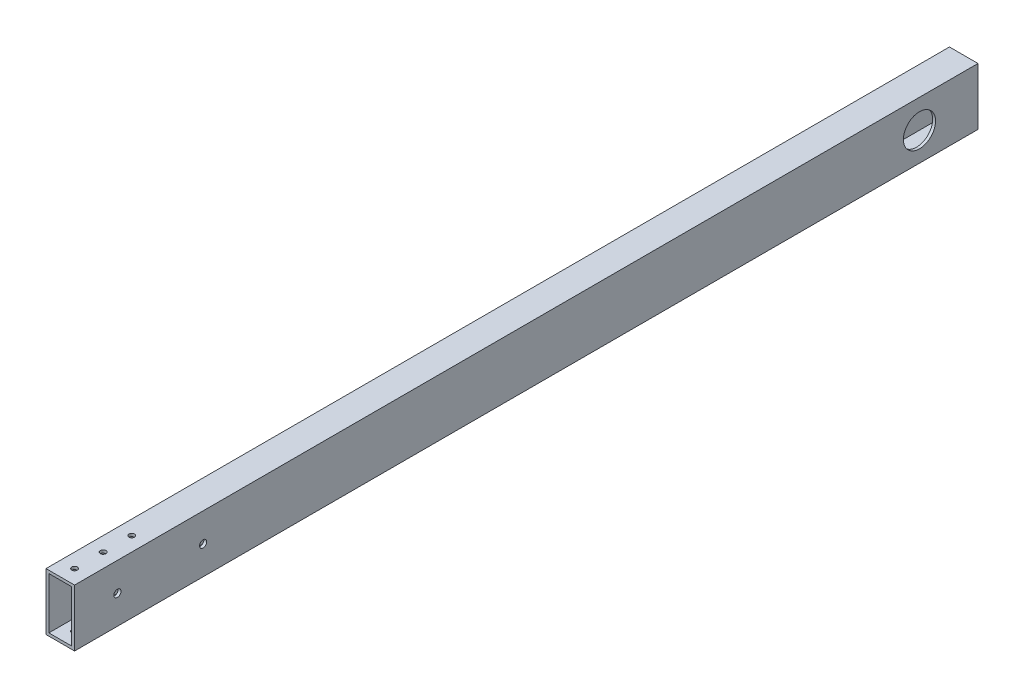
from build123d import *

# Parameters (mm, degrees)
SKETCH1_W           = 25.4
SKETCH1_H           = 50.8
SKETCH1_W_2         = 20.32
SKETCH1_H_2         = 45.72
EXTRUDE_THIN1_DEPTH = 401.6375
SKETCH2_R           = 14.2875
CUT_EXTRUDE1_DEPTH  = 26.4
SKETCH3_R           = 3.175
CUT_EXTRUDE2_DEPTH  = 26.4
SKETCH5_R           = 2.4765
CUT_EXTRUDE4_DEPTH  = 3.81
SKETCH7_R           = 2.4765
CUT_EXTRUDE5_DEPTH  = 51.8
SKETCH8_R           = 2.476504233
CUT_EXTRUDE6_DEPTH  = 3.81


with BuildPart() as part:
    # Sketch1 → Extrude-Thin1 (new body, symmetric)
    with BuildSketch(Plane.XY):
        Rectangle(SKETCH1_W, SKETCH1_H)
        Rectangle(SKETCH1_W_2, SKETCH1_H_2, mode=Mode.SUBTRACT)
    extrude(amount=EXTRUDE_THIN1_DEPTH, both=True)

    # Sketch2 → Cut-Extrude1 (cut, through all)
    with BuildSketch(Plane.ZY.offset(12.7)):
        with Locations((-349.59481695, 0)):
            Circle(SKETCH2_R)
    extrude(amount=-CUT_EXTRUDE1_DEPTH, mode=Mode.SUBTRACT)

    # Sketch3 → Cut-Extrude2 (cut, through all)
    with BuildSketch(Plane.ZY.offset(12.7)):
        with Locations((363.5375, 0)):
            Circle(SKETCH3_R)
        with Locations((287.3375, 0)):
            Circle(SKETCH3_R)
    extrude(amount=-CUT_EXTRUDE2_DEPTH, mode=Mode.SUBTRACT)

    # Sketch5 → Cut-Extrude4 (cut)
    with BuildSketch(Plane.XZ.offset(25.4)):
        with Locations((-5.11e-06, 228.865824925)):
            Circle(SKETCH5_R)
        with Locations((0, 152.665824925)):
            Circle(SKETCH5_R)
    extrude(amount=-CUT_EXTRUDE4_DEPTH, mode=Mode.SUBTRACT)

    # Sketch7 → Cut-Extrude5 (cut, through all)
    with BuildSketch(Plane(origin=(0, 25.4, 0), x_dir=(1, 0, 0), z_dir=(0, 1, 0))):
        with Locations((0, -338.1375)):
            Circle(SKETCH7_R)
        with Locations((0, -363.5375)):
            Circle(SKETCH7_R)
        with Locations((0, -388.9375)):
            Circle(SKETCH7_R)
    extrude(amount=-CUT_EXTRUDE5_DEPTH, mode=Mode.SUBTRACT)

    # Sketch8 → Cut-Extrude6 (cut)
    with BuildSketch(Plane.XZ.offset(25.4)):
        with Locations((-5.001306037, -196.8119)):
            Circle(SKETCH8_R)
        with Locations((-5.048266279, -184.111986821)):
            Circle(SKETCH8_R)
    extrude(amount=-CUT_EXTRUDE6_DEPTH, mode=Mode.SUBTRACT)


solid = part.part
